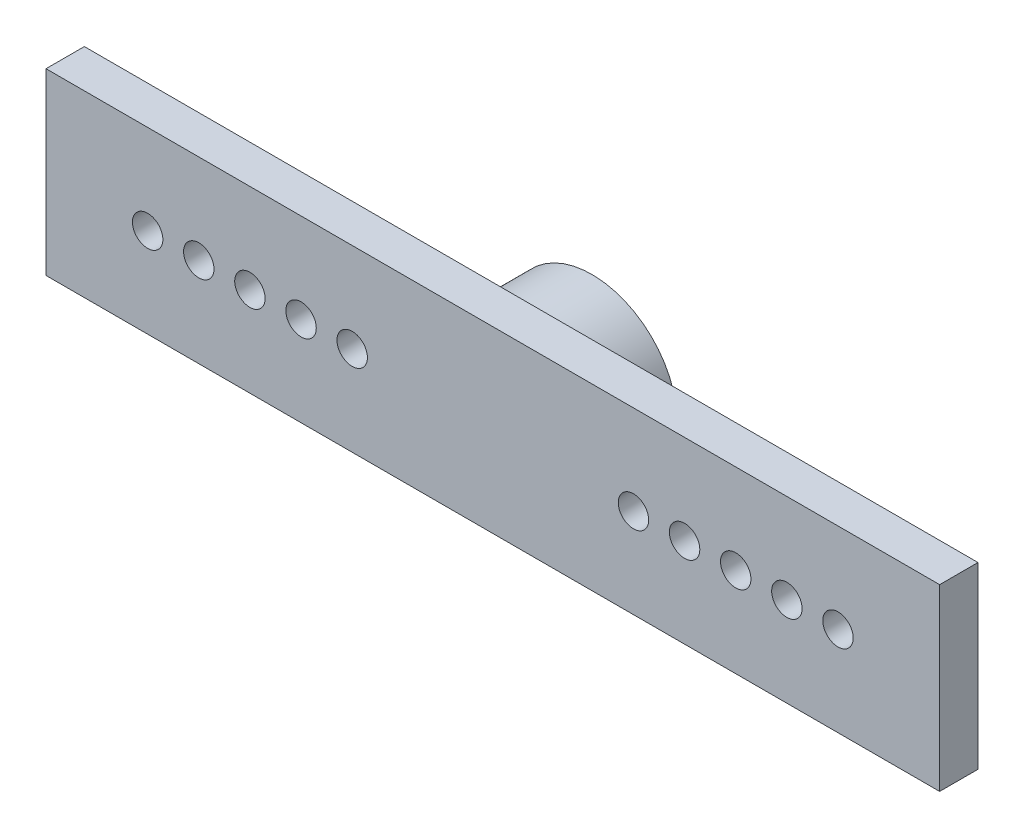
from build123d import *

# Parameters (mm, degrees)
SKETCH1_W         = 44.38767267
SKETCH1_H         = 8.89569146
EXTRUDE1_DEPTH    = 1.905
SKETCH2_R         = 4.2291
SKETCH2_R_2       = 2.9718
EXTRUDE2_DEPTH    = 3.0226
LPATTERN2_COUNT   = 5
LPATTERN2_PITCH   = 2.54
CIRPATTERN2_COUNT = 2


with BuildPart() as part:
    # Sketch1 → Extrude1 (new body)
    with BuildSketch(Plane.XY):
        Rectangle(SKETCH1_W, SKETCH1_H)
    extrude(amount=EXTRUDE1_DEPTH)

    # Sketch2 → Extrude2 (add)
    with BuildSketch(Plane(origin=(0, 0, 0), x_dir=(-1, 0, 0), z_dir=(0, 0, -1))):
        Circle(SKETCH2_R)
        Circle(SKETCH2_R_2, mode=Mode.SUBTRACT)
    extrude(amount=EXTRUDE2_DEPTH)

    # Sketch4 → #53 (0.0595) Diameter Hole1 (revolve, cut)
    with BuildSketch(Plane(origin=(6.985, 0, 1.905), x_dir=(0, -1, 0), z_dir=(1, 0, 0))):
        Polygon((0, 0), (0, 5.534040327), (0.75565, 5.08), (0.75565, 0), align=None)
    f_53_0_0595_diameter_hole1 = revolve(axis=Axis((6.985, 0, 8.255), (0, 0, -1)), mode=Mode.SUBTRACT)

    # LPattern2: #53 (0.0595) Diameter Hole1 ×5
    with Locations(*[(i * LPATTERN2_PITCH, 0, 0) for i in range(1, LPATTERN2_COUNT)]):
        add(f_53_0_0595_diameter_hole1, mode=Mode.SUBTRACT)

    # CirPattern2: #53 (0.0595) Diameter Hole1 ×2 about axis
    cirpattern2_axis = Axis((0, 0, 0), (0, 0, 1))
    for i in range(1, CIRPATTERN2_COUNT):
        add(f_53_0_0595_diameter_hole1.rotate(cirpattern2_axis, i * 360 / CIRPATTERN2_COUNT), mode=Mode.SUBTRACT)

    # CirPattern2 copy 1 sketch → CirPattern2 copy 1 (revolve, cut)
    with BuildSketch(Plane(origin=(-9.525, 0, 1.905), x_dir=(0, 1, 0), z_dir=(-1, 0, 0))):
        Polygon((0, 0), (0, 5.534040327), (0.75565, 5.08), (0.75565, 0), align=None)
    revolve(axis=Axis((-9.525, 0, 8.255), (0, 0, -1)), mode=Mode.SUBTRACT)

    # CirPattern2 copy 2 sketch → CirPattern2 copy 2 (revolve, cut)
    with BuildSketch(Plane(origin=(-12.065, 0, 1.905), x_dir=(0, 1, 0), z_dir=(-1, 0, 0))):
        Polygon((0, 0), (0, 5.534040327), (0.75565, 5.08), (0.75565, 0), align=None)
    revolve(axis=Axis((-12.065, 0, 8.255), (0, 0, -1)), mode=Mode.SUBTRACT)

    # CirPattern2 copy 3 sketch → CirPattern2 copy 3 (revolve, cut)
    with BuildSketch(Plane(origin=(-14.605, 0, 1.905), x_dir=(0, 1, 0), z_dir=(-1, 0, 0))):
        Polygon((0, 0), (0, 5.534040327), (0.75565, 5.08), (0.75565, 0), align=None)
    revolve(axis=Axis((-14.605, 0, 8.255), (0, 0, -1)), mode=Mode.SUBTRACT)

    # CirPattern2 copy 4 sketch → CirPattern2 copy 4 (revolve, cut)
    with BuildSketch(Plane(origin=(-17.145, 0, 1.905), x_dir=(0, 1, 0), z_dir=(-1, 0, 0))):
        Polygon((0, 0), (0, 5.534040327), (0.75565, 5.08), (0.75565, 0), align=None)
    revolve(axis=Axis((-17.145, 0, 8.255), (0, 0, -1)), mode=Mode.SUBTRACT)


solid = part.part
